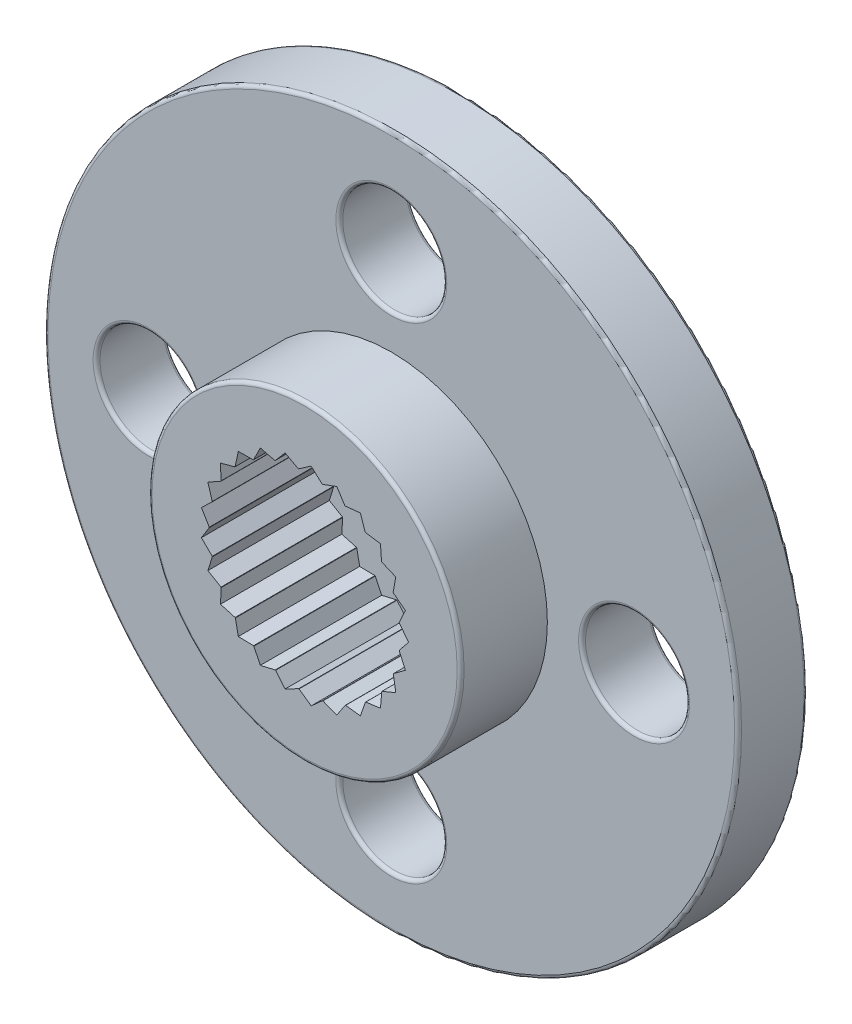
from build123d import *

# Parameters (mm, degrees)
SKETCH1_R           = 10
BOSS_EXTRUDE1_DEPTH = 2
SKETCH2_R           = 4.5
BOSS_EXTRUDE2_DEPTH = 2.5
SKETCH3_R           = 2.75
CUT_EXTRUDE1_DEPTH  = 3.5
SKETCH4_R           = 1.5
CUT_EXTRUDE2_DEPTH  = 2
CUT_EXTRUDE3_DEPTH  = 3.5
CIRPATTERN1_COUNT   = 25
SKETCH6_R           = 1.5
CUT_EXTRUDE4_DEPTH  = 3
FILLET1_R           = 0.1
FILLET2_R           = 0.1


with BuildPart() as part:
    # Sketch1 → Boss-Extrude1 (new body)
    with BuildSketch(Plane.XY):
        Circle(SKETCH1_R)
    extrude(amount=BOSS_EXTRUDE1_DEPTH)

    # Sketch2 → Boss-Extrude2 (add)
    with BuildSketch(Plane.XY.offset(2)):
        Circle(SKETCH2_R)
    extrude(amount=BOSS_EXTRUDE2_DEPTH)

    # Sketch3 → Cut-Extrude1 (cut)
    with BuildSketch(Plane.XY.offset(4.5)):
        Circle(SKETCH3_R)
    extrude(amount=-CUT_EXTRUDE1_DEPTH, mode=Mode.SUBTRACT)

    # Sketch4 → Cut-Extrude2 (cut, through all)
    with BuildSketch(Plane.XY.offset(1)):
        Circle(SKETCH4_R)
    extrude(amount=-CUT_EXTRUDE2_DEPTH, mode=Mode.SUBTRACT)

    # Sketch5 → Cut-Extrude3 (cut)
    with BuildSketch(Plane.XY.offset(4.5)):
        Polygon((-2.656507983, 0.682075321), (-2.682344512, 0.606240809), (-2.75, 0), (-2.976344104, 0.375999701), align=None)
    cut_extrude3 = extrude(amount=-CUT_EXTRUDE3_DEPTH, mode=Mode.SUBTRACT)

    # CirPattern1: Cut-Extrude3 ×25 about axis
    cirpattern1_axis = Axis((0, 0, 0), (0, 0, 1))
    for i in range(1, CIRPATTERN1_COUNT):
        add(cut_extrude3.rotate(cirpattern1_axis, i * 360 / CIRPATTERN1_COUNT), mode=Mode.SUBTRACT)

    # Sketch6 → Cut-Extrude4 (cut, through all)
    with BuildSketch(Plane.XY.offset(2)):
        with Locations((-7, 0)):
            Circle(SKETCH6_R)
        with Locations((7, 0)):
            Circle(SKETCH6_R)
        with Locations((0, 7)):
            Circle(SKETCH6_R)
        with Locations((0, -7)):
            Circle(SKETCH6_R)
    extrude(amount=-CUT_EXTRUDE4_DEPTH, mode=Mode.SUBTRACT)

    # Fillet1
    fillet1_edges = [part.edges().sort_by_distance(p)[0] for p in [
        (5.5, 0, 2),
    ]]
    fillet(fillet1_edges, radius=FILLET1_R)

    # Fillet2
    fillet2_edges = [part.edges().sort_by_distance(p)[0] for p in [
        (-1.5, 0, 0),
        (-1.5, 0, 1),
        (-10, 0, 0),
        (-8.5, 0, 0),
        (-8.5, 0, 2),
        (-10, 0, 2),
        (5.5, 0, 0),
        (-1.5, 7, 0),
        (-1.5, 7, 2),
        (-1.5, -7, 0),
        (-1.5, -7, 2),
        (-4.5, 0, 4.5),
    ]]
    fillet(fillet2_edges, radius=FILLET2_R)


solid = part.part
